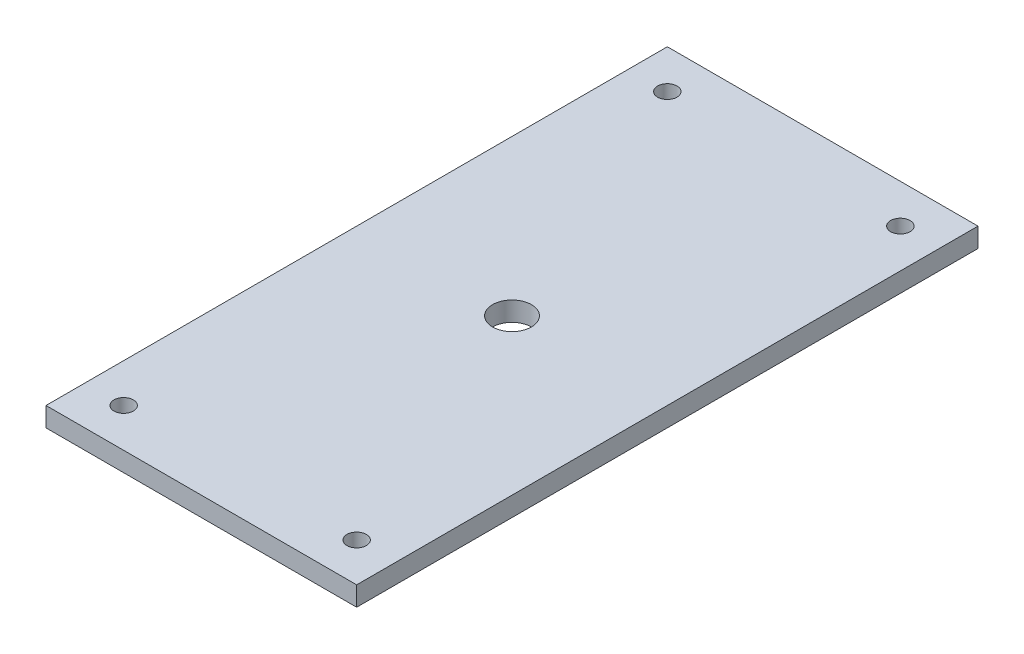
from build123d import *

# Parameters (mm, degrees)
SKETCH1_W           = 50.8
SKETCH1_H           = 101.6
SKETCH1_R           = 1.5875
SKETCH1_R_2         = 3.175
BOSS_EXTRUDE1_DEPTH = 3.175


with BuildPart() as part:
    # Sketch1 → Boss-Extrude1 (new body)
    with BuildSketch(Plane(origin=(0, 0, 0), x_dir=(1, 0, 0), z_dir=(0, 1, 0))):
        with Locations((-25.4, 50.8)):
            Rectangle(SKETCH1_W, SKETCH1_H)
        with Locations((-44.45, 6.35)):
            Circle(SKETCH1_R, mode=Mode.SUBTRACT)
        with Locations((-44.45, 95.25)):
            Circle(SKETCH1_R, mode=Mode.SUBTRACT)
        with Locations((-6.35, 6.35)):
            Circle(SKETCH1_R, mode=Mode.SUBTRACT)
        with Locations((-6.35, 95.25)):
            Circle(SKETCH1_R, mode=Mode.SUBTRACT)
        with Locations((-25.4, 50.8)):
            Circle(SKETCH1_R_2, mode=Mode.SUBTRACT)
    extrude(amount=BOSS_EXTRUDE1_DEPTH)


solid = part.part
